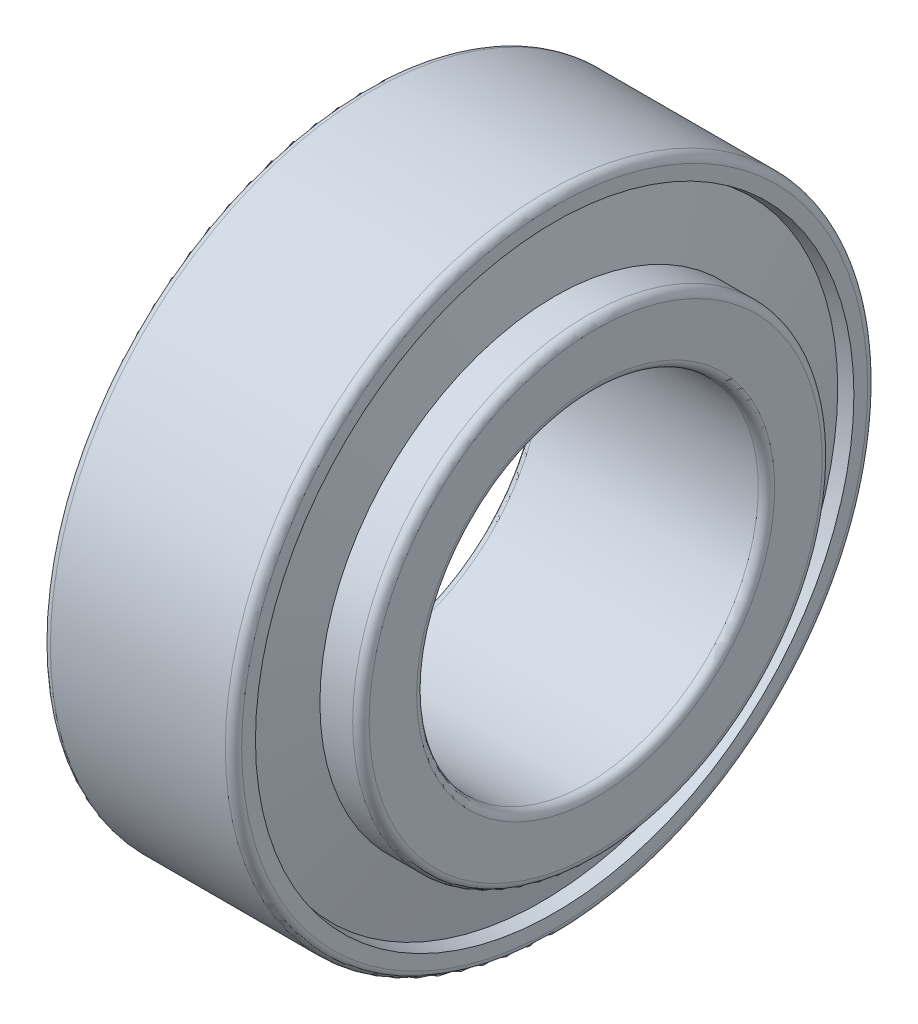
from build123d import *


with BuildPart() as part:
    # Эскиз1 → Повернуть1 (revolve)
    with BuildSketch(Plane.XY):
        with BuildLine():
            Line((0.970205183, 19.32988738), (0, 19.139))
            Line((0, 19.139), (0, 22.9))
            ThreePointArc((0, 22.9), (0.175735931, 23.324264069), (0.6, 23.5))
            Line((0.6, 23.5), (13.4, 23.5))
            ThreePointArc((13.4, 23.5), (13.824264069, 23.324264069), (14, 22.9))
            Line((14, 22.9), (14, 21.893492934))
            Line((14, 21.893492934), (13.012426118, 21.699188271))
            Line((13.012426118, 21.699188271), (14, 16.578811729))
            Line((14, 16.578811729), (14, 17.178811729))
            Line((14, 17.178811729), (16.4, 17.178811729))
            ThreePointArc((16.4, 17.178811729), (16.824264069, 17.003075798), (17, 16.578811729))
            Line((17, 16.578811729), (17, 13.1))
            ThreePointArc((17, 13.1), (16.824264069, 12.675735931), (16.4, 12.5))
            Line((16.4, 12.5), (0.6, 12.5))
            ThreePointArc((0.6, 12.5), (0.175735931, 12.675735931), (0, 13.1))
            Line((0, 13.1), (0, 14.299564132))
            Line((0, 14.299564132), (1.940410366, 14.299564132))
            Line((1.940410366, 14.299564132), (0.970205183, 19.32988738))
        make_face()
    revolve(axis=Axis((-882.527700014, 0, 0), (1, 0, 0)))


solid = part.part
